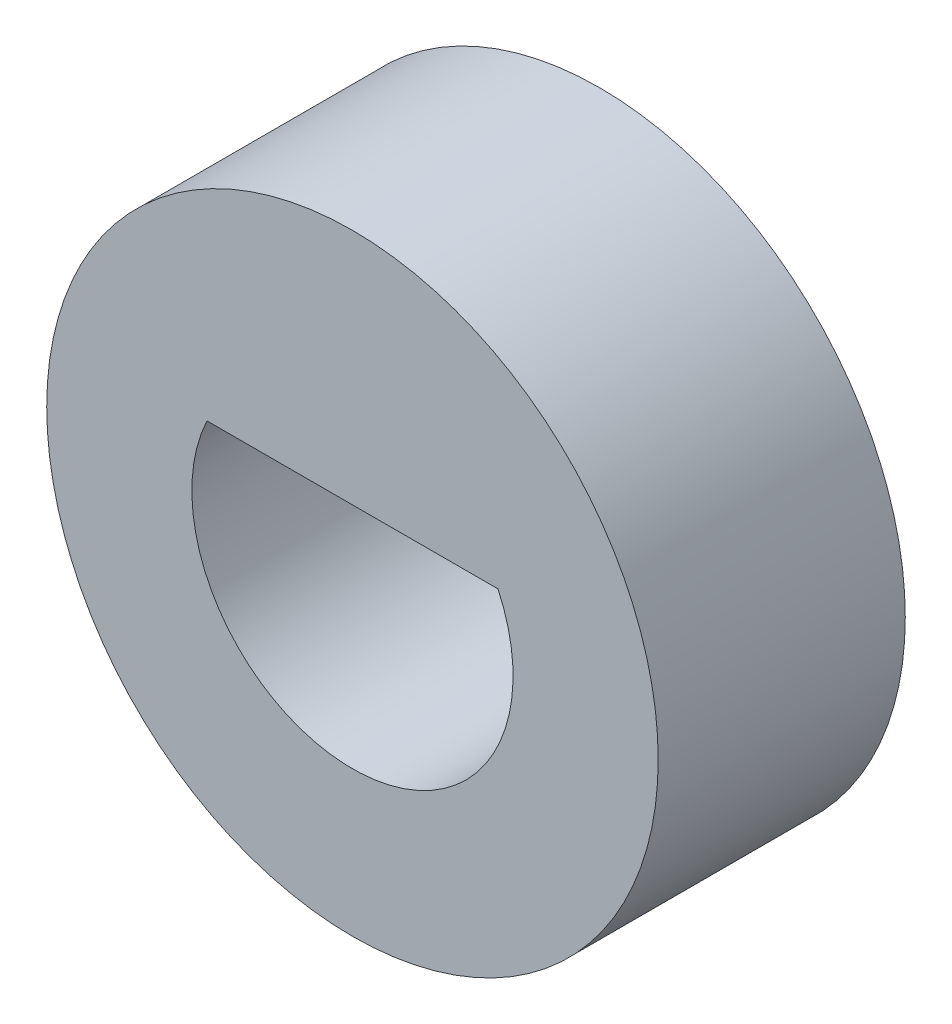
from build123d import *

# Parameters (mm, degrees)
SKIZZE1_R                       = 4.95
AUFSATZ_LINEAR_AUSTRAGEN1_DEPTH = 4


with BuildPart() as part:
    # Skizze1 → Aufsatz-Linear austragen1 (new body)
    with BuildSketch(Plane.XY):
        Circle(SKIZZE1_R)
        with BuildLine():
            Line((-2.355843798, 1.1), (2.355843798, 1.1))
            ThreePointArc((2.355843798, 1.1), (0, -2.6), (-2.355843798, 1.1))
        make_face(mode=Mode.SUBTRACT)
    extrude(amount=AUFSATZ_LINEAR_AUSTRAGEN1_DEPTH)


solid = part.part
